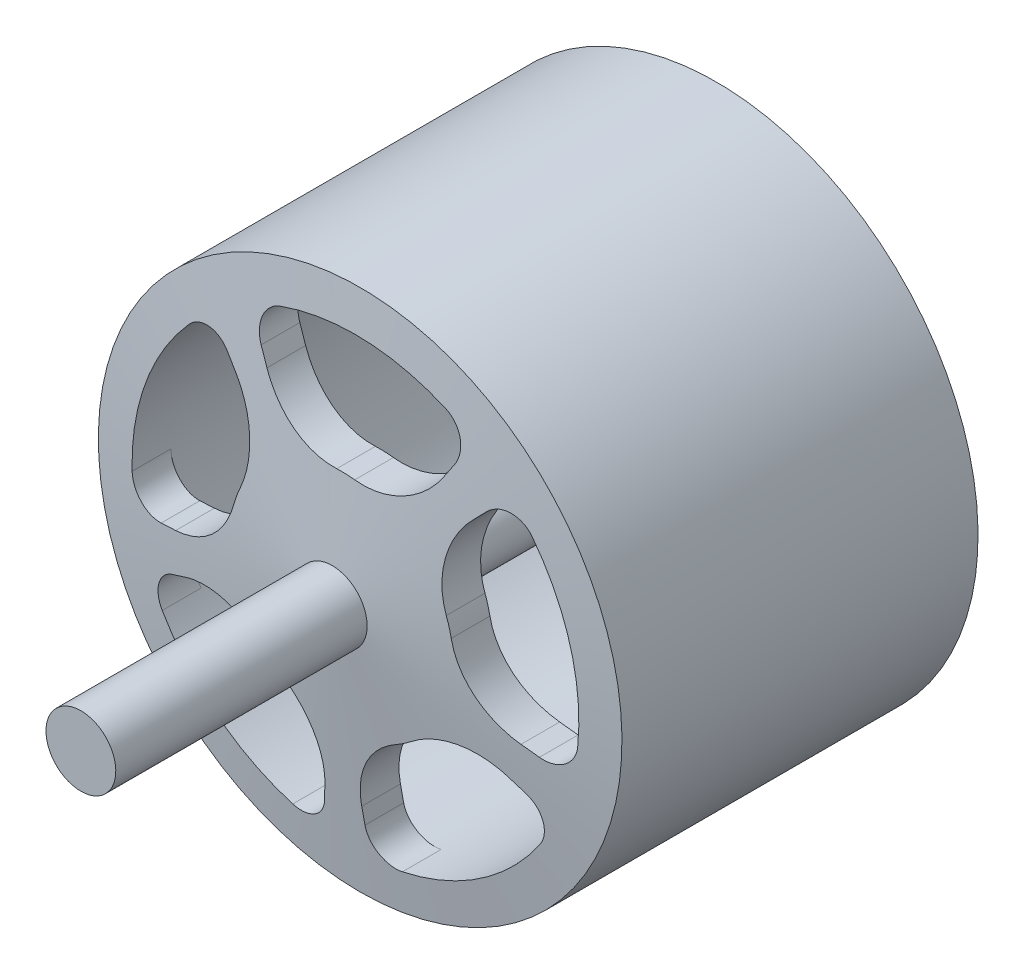
from build123d import *

# Parameters (mm, degrees)
CUT_EXTRUDE1_DEPTH = 46.5
CIRPATTERN1_COUNT  = 5


with BuildPart() as part:
    # Sketch1 → Revolve1 (revolve)
    with BuildSketch(Plane(origin=(0, 0, 0), x_dir=(0, 0, -1), z_dir=(1, 0, 0))):
        Polygon((-45.5, 0), (-45.5, 2.5), (-27.5, 2.5), (-25.5, 18.75), (0, 18.75), (0, 16), (-23.067711421, 16), (-24.729249883, 2.5), (7.7, 2.5), (7.7, 0), (0, 0), align=None)
    revolve(axis=Axis((0, 0, 45.5), (0, 0, -1)))

    # Sketch2 → Cut-Extrude1 (cut, through all)
    with BuildSketch(Plane.XY):
        with BuildLine():
            Line((-6.488637759, 12.243266722), (-5.92328878, 11.176522269))
            ThreePointArc((-5.92328878, 11.176522269), (-3.600547795, 8.777820958), (-0.355313587, 7.992105621))
            ThreePointArc((-0.355313587, 7.992105621), (0.290007789, 7.99474174), (0.933442091, 7.945356245))
            ThreePointArc((0.933442091, 7.945356245), (4.227075409, 8.493875363), (6.717507821, 10.717979692))
            Line((6.717507821, 10.717979692), (7.358661127, 11.740958497))
            ThreePointArc((7.358661127, 11.740958497), (7.576311791, 13.38880522), (6.47314256, 14.632102562))
            ThreePointArc((6.47314256, 14.632102562), (0.580015579, 15.989483479), (-5.395970771, 15.06265247))
            ThreePointArc((-5.395970771, 15.06265247), (-6.58632281, 13.90255219), (-6.488637759, 12.243266722))
        make_face()
    cut_extrude1 = extrude(amount=CUT_EXTRUDE1_DEPTH, mode=Mode.SUBTRACT)

    # CirPattern1: Cut-Extrude1 ×5 about axis
    cirpattern1_axis = Axis((0, 0, 0), (0, 0, 1))
    for i in range(1, CIRPATTERN1_COUNT):
        add(cut_extrude1.rotate(cirpattern1_axis, i * 360 / CIRPATTERN1_COUNT), mode=Mode.SUBTRACT)


solid = part.part
